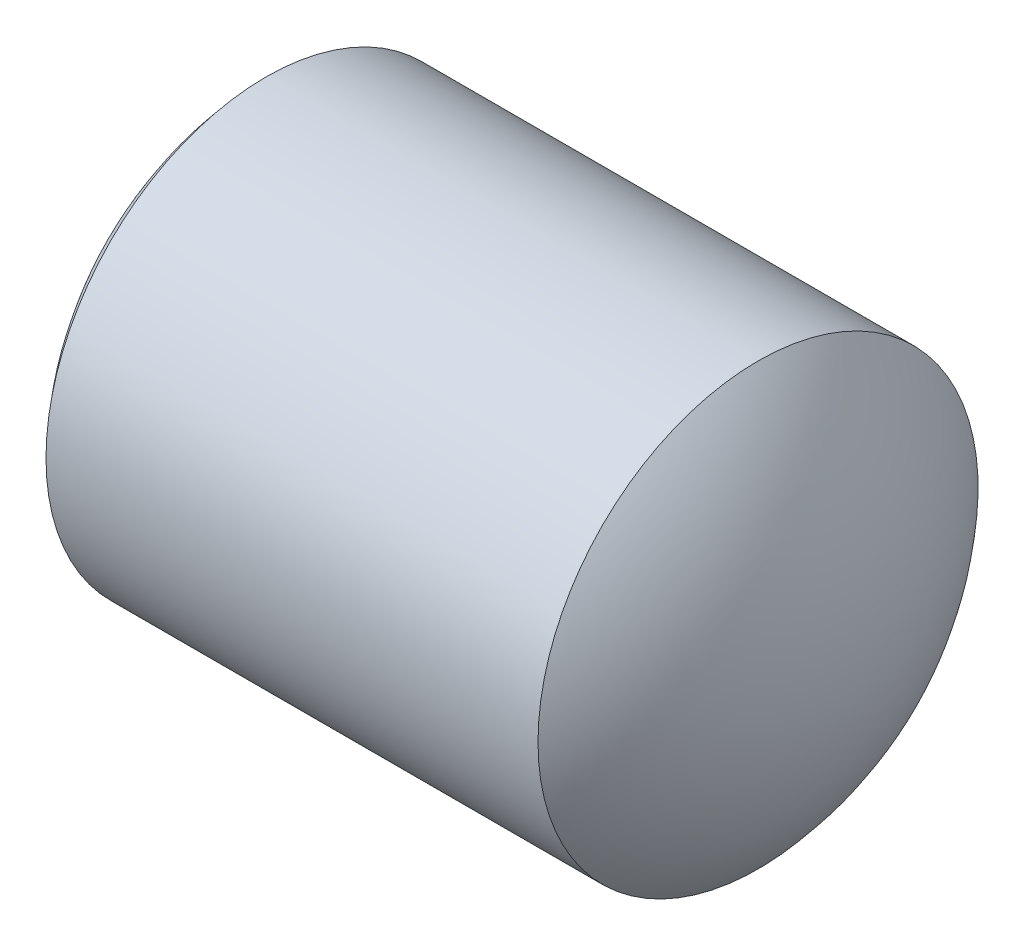
from build123d import *


with BuildPart() as part:
    # 草图1 one side → 旋转1 (revolve)
    with BuildSketch(Plane.XY):
        with BuildLine():
            Line((235.108062935, 134.34486375), (232.871994957, 134.34486375))
            ThreePointArc((232.871994957, 134.34486375), (232.588770407, 133.880096884), (232.490028946, 133.34486375))
            Line((232.490028946, 133.34486375), (235.490028946, 133.34486375))
            ThreePointArc((235.490028946, 133.34486375), (235.391287484, 133.880096884), (235.108062935, 134.34486375))
        make_face()
    revolve(axis=Axis((232.248492044, 133.34486375, 0), (1, 0, 0)))


solid = part.part
